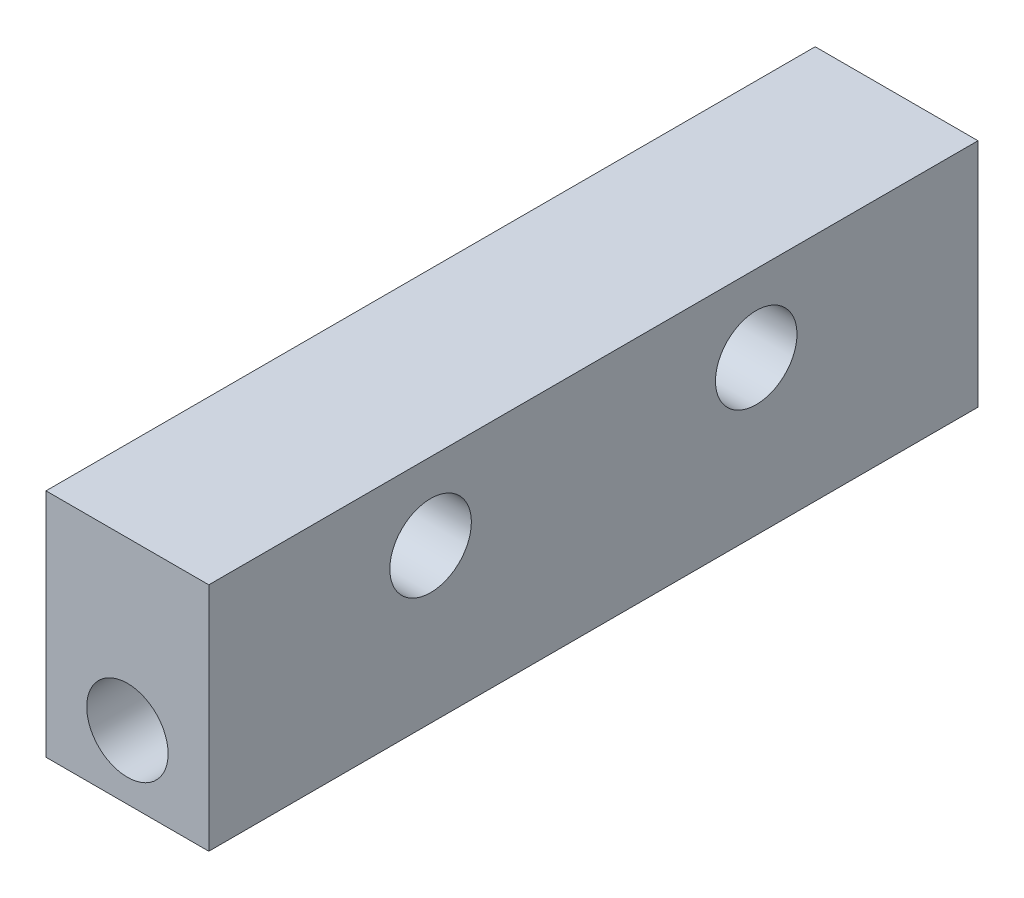
from build123d import *

# Parameters (mm, degrees)
SKETCH1_W           = 6.35
SKETCH1_H           = 9
SKETCH1_R           = 1.5875
BOSS_EXTRUDE1_DEPTH = 30
SKETCH2_R           = 1.59
CUT_EXTRUDE1_DEPTH  = 30


with BuildPart() as part:
    # Sketch1 → Boss-Extrude1 (new body)
    with BuildSketch(Plane.XY):
        with Locations((3.175, -4.5)):
            Rectangle(SKETCH1_W, SKETCH1_H)
        with Locations((3.175, -6.5)):
            Circle(SKETCH1_R, mode=Mode.SUBTRACT)
    extrude(amount=BOSS_EXTRUDE1_DEPTH)

    # Sketch2 → Cut-Extrude1 (cut)
    with BuildSketch(Plane(origin=(0, 0, 0), x_dir=(0, 0, -1), z_dir=(1, 0, 0))):
        with Locations((-21.35, -3)):
            Circle(SKETCH2_R)
        with Locations((-8.65, -3)):
            Circle(SKETCH2_R)
    extrude(amount=CUT_EXTRUDE1_DEPTH, mode=Mode.SUBTRACT)


solid = part.part
